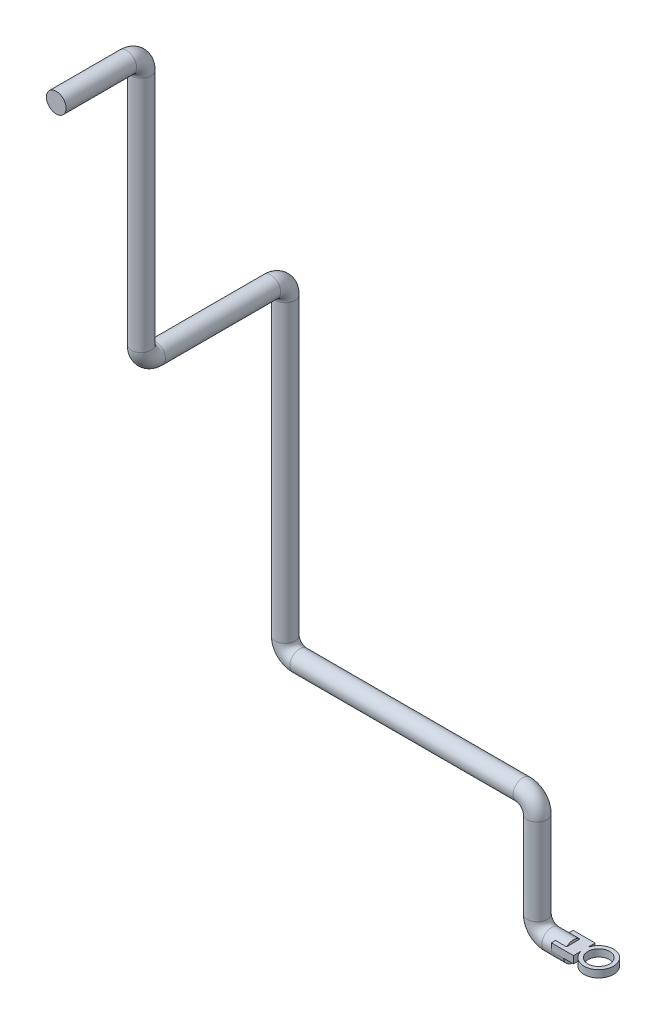
from build123d import *

# Parameters (mm, degrees)
CROQUIS1_R              = 13.7
CROQUIS2_R              = 20.515824583
CROQUIS2_R_2            = 15.073303007
CROQUIS2_W              = 30.644249184
CROQUIS2_H              = 30.146606014
SALIENTE_EXTRUIR1_DEPTH = 10


with BuildPart() as part:
    # Barrer1: sweep along a curve in space
    with BuildLine() as barrer1_path:
        Line((0, 0, 0), (-30, 0, 0))
        ThreePointArc((-30, 0, 0), (-44.142135624, 5.857864376, 0), (-50, 20, 0))
        Line((-50, 20, 0), (-50, 140, 0))
        ThreePointArc((-50, 140, 0), (-55.857864376, 154.142135624, 0), (-70, 160, 0))
        Line((-70, 160, 0), (-380, 160, 0))
        ThreePointArc((-380, 160, 0), (-394.142135624, 165.857864376, 0), (-400, 180, 0))
        Line((-400, 180, 0), (-400, 589.49, 0))
        ThreePointArc((-400, 589.49, 0), (-400, 603.632135624, 5.857864376), (-400, 609.49, 20))
        Line((-400, 609.49, 20), (-400, 609.49, 180))
        ThreePointArc((-400, 609.49, 180), (-400, 615.347864376, 194.142135624), (-400, 629.49, 200))
        Line((-400, 629.49, 200), (-400, 959.49, 200))
        ThreePointArc((-400, 959.49, 200), (-400, 973.632135624, 205.857864376), (-400, 979.49, 220))
        Line((-400, 979.49, 220), (-400, 979.49, 318))
    # Croquis1 → Barrer1 (sweep)
    with BuildSketch(Plane(origin=(0, 0, 0), x_dir=(0, 0, -1), z_dir=(1, 0, 0))):
        Circle(CROQUIS1_R)
    sweep(path=barrer1_path.line)

    # Croquis2 → Saliente-Extruir1 (add)
    with BuildSketch(Plane(origin=(0, 0, 0), x_dir=(1, 0, 0), z_dir=(0, 1, 0))):
        with Locations((35.335783032, 0)):
            Circle(CROQUIS2_R)
        with Locations((35.335783032, 0)):
            Circle(CROQUIS2_R_2, mode=Mode.SUBTRACT)
        Rectangle(CROQUIS2_W, CROQUIS2_H)
    extrude(amount=SALIENTE_EXTRUIR1_DEPTH)


solid = part.part
